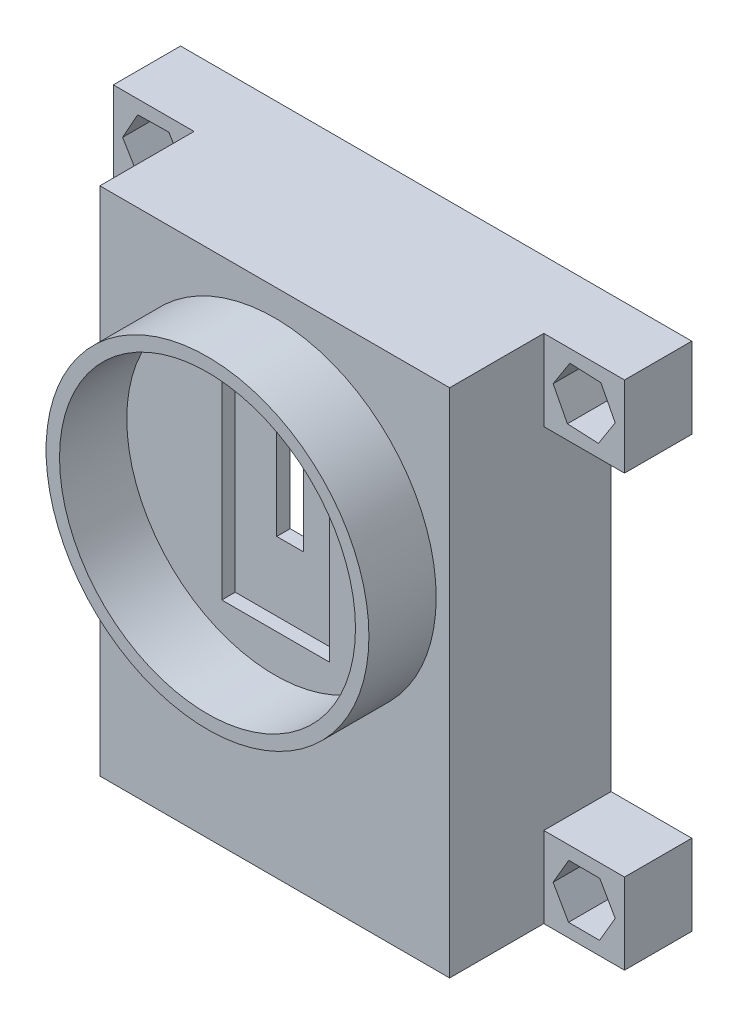
from build123d import *

# Parameters (mm, degrees)
SKETCH_1_W          = 26
SKETCH_1_H          = 38
EXTRUDE_1_DEPTH     = 12
SKETCH_2_W          = 22
SKETCH_2_H          = 34
CUT_EXTRUDE_1_DEPTH = 10
SKETCH_3_W          = 2
SKETCH_3_H          = 7
CUT_EXTRUDE_3_DEPTH = 12
SKETCH_4_W          = 6
SKETCH_4_H          = 6
EXTRUDE_2_DEPTH     = 5
SKETCH_5_R          = 1
CUT_EXTRUDE_4_DEPTH = 13
CUT_EXTRUDE_START   = 1
CUT_EXTRUDE_5_DEPTH = 4
SKETCH_7_R          = 12
SKETCH_7_R_2        = 11
EXTRUDE_3_DEPTH     = 5
SKETCH_9_W          = 8
SKETCH_9_H          = 15
CUT_EXTRUDE_7_DEPTH = 1
SKETCH_10_W         = 14.41096837
SKETCH_10_H         = 3
EXTRUDE_4_DEPTH     = 2


with BuildPart() as part:
    # ｽｹｯﾁ1 → ﾎﾞｽ - 押し出し1 (new body)
    with BuildSketch(Plane.XY):
        Rectangle(SKETCH_1_W, SKETCH_1_H)
    extrude(amount=EXTRUDE_1_DEPTH)

    # ｽｹｯﾁ2 → ｶｯﾄ - 押し出し1 (cut)
    with BuildSketch(Plane.XY):
        Rectangle(SKETCH_2_W, SKETCH_2_H)
    extrude(amount=CUT_EXTRUDE_1_DEPTH, mode=Mode.SUBTRACT)

    # ｽｹｯﾁ3 → ｶｯﾄ - 押し出し3 (cut)
    with BuildSketch(Plane.XY):
        with Locations((0.147807357, 5.5)):
            Rectangle(SKETCH_3_W, SKETCH_3_H)
    extrude(amount=CUT_EXTRUDE_3_DEPTH, mode=Mode.SUBTRACT)

    # ｽｹｯﾁ4 → ﾎﾞｽ - 押し出し2 (add)
    with BuildSketch(Plane.XY):
        with Locations((16, 16)):
            Rectangle(SKETCH_4_W, SKETCH_4_H)
        with Locations((16, -16)):
            Rectangle(SKETCH_4_W, SKETCH_4_H)
        with Locations((-16, -16)):
            Rectangle(SKETCH_4_W, SKETCH_4_H)
        with Locations((-16, 16)):
            Rectangle(SKETCH_4_W, SKETCH_4_H)
    extrude(amount=EXTRUDE_2_DEPTH)

    # ｽｹｯﾁ5 → ｶｯﾄ - 押し出し4 (cut, through all)
    with BuildSketch(Plane.XY):
        with Locations((-16, 16)):
            Circle(SKETCH_5_R)
        with Locations((-16, -16)):
            Circle(SKETCH_5_R)
        with Locations((16, -16)):
            Circle(SKETCH_5_R)
        with Locations((16, 16)):
            Circle(SKETCH_5_R)
    extrude(amount=CUT_EXTRUDE_4_DEPTH, mode=Mode.SUBTRACT)

    # ｽｹｯﾁ6 → ｶｯﾄ - 押し出し5 (cut)
    with BuildSketch(Plane.XY.offset(CUT_EXTRUDE_START)):
        Polygon((-17.184124892, 17.98272075), (-18.309148984, 15.965878137), (-17.125024092, 13.983157387), (-14.815875108, 14.01727925), (-13.690851016, 16.034121863), (-14.874975908, 18.016842613), align=None)
        Polygon((-17.07560545, -13.956374239), (-18.307634549, -15.909688764), (-17.2320291, -17.953314524), (-14.92439455, -18.043625761), (-13.692365451, -16.090311236), (-14.7679709, -14.046685476), align=None)
        Polygon((14.939341307, 18.051423035), (13.693086191, 16.107154145), (14.753744884, 14.055731109), (17.060658693, 13.948576965), (18.306913809, 15.892845855), (17.246255116, 17.944268891), align=None)
        Polygon((14.854466591, -13.994735294), (13.690623119, -15.98942868), (14.836156527, -17.994693386), (17.145533409, -18.005264706), (18.309376881, -16.01057132), (17.163843473, -14.005306614), align=None)
    extrude(amount=CUT_EXTRUDE_5_DEPTH, mode=Mode.SUBTRACT)

    # ｽｹｯﾁ7 → ﾎﾞｽ - 押し出し3 (add)
    with BuildSketch(Plane.XY.offset(12)):
        with Locations((0, 5)):
            Circle(SKETCH_7_R)
        with Locations((0, 5)):
            Circle(SKETCH_7_R_2, mode=Mode.SUBTRACT)
    extrude(amount=EXTRUDE_3_DEPTH)

    # ｽｹｯﾁ9 → ｶｯﾄ - 押し出し7 (cut)
    with BuildSketch(Plane.XY.offset(12)):
        with Locations((0.061272904, 4.367214105)):
            Rectangle(SKETCH_9_W, SKETCH_9_H)
    extrude(amount=-CUT_EXTRUDE_7_DEPTH, mode=Mode.SUBTRACT)

    # ｽｹｯﾁ10 → ﾎﾞｽ - 押し出し4 (add)
    with BuildSketch(Plane.XY.offset(10)):
        with Locations((0, -11.5)):
            Rectangle(SKETCH_10_W, SKETCH_10_H)
    extrude(amount=-EXTRUDE_4_DEPTH)


solid = part.part
